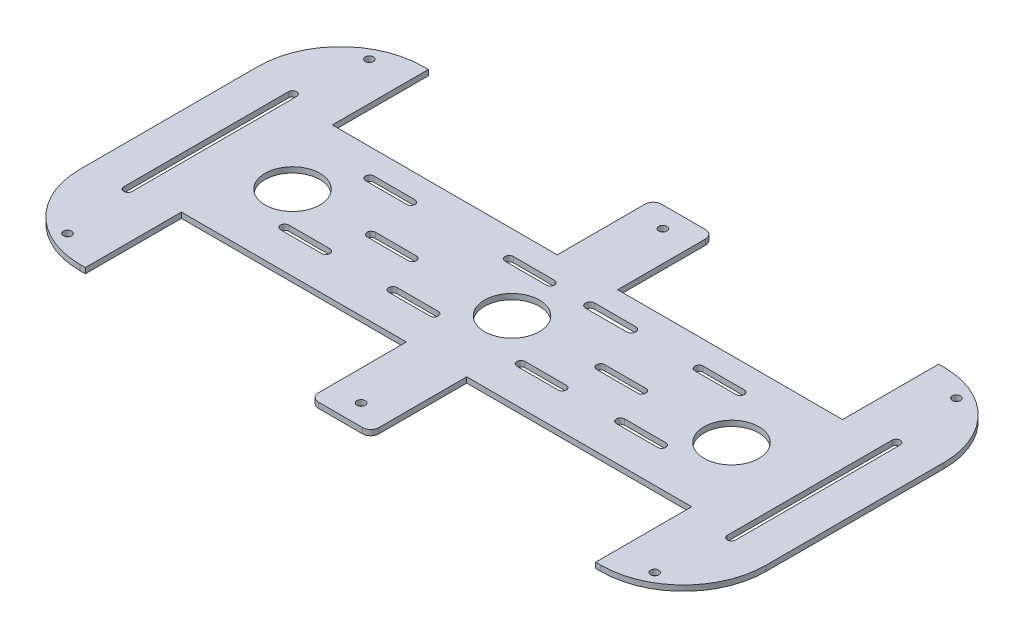
from build123d import *

# Parameters (mm, degrees)
SKETCH_1_R          = 10
EXTRUDE_1_DEPTH     = 2
FILLET_1_R          = 3
SKETCH_2_R          = 1.5
CUT_EXTRUDE_1_DEPTH = 3
SKETCH_3_R          = 1.5
CUT_EXTRUDE_2_DEPTH = 10


with BuildPart() as part:
    # 草图1 → 凸台-拉伸1 (new body)
    with BuildSketch(Plane(origin=(0, 0, 0), x_dir=(1, 0, 0), z_dir=(0, 1, 0))):
        with BuildLine():
            ThreePointArc((-125, -32.5), (-116.213203436, -53.713203436), (-95, -62.5))
            Line((-95, -62.5), (-93, -62.5))
            Line((-93, -62.5), (-93, -27.5))
            Line((-93, -27.5), (-11, -27.5))
            Line((-11, -27.5), (-11, -62.5))
            Line((-11, -62.5), (11, -62.5))
            Line((11, -62.5), (11, -27.5))
            Line((11, -27.5), (93, -27.5))
            Line((93, -27.5), (93, -62.5))
            Line((93, -62.5), (95, -62.5))
            ThreePointArc((95, -62.5), (116.213203436, -53.713203436), (125, -32.5))
            Line((125, -32.5), (125, 32.5))
            ThreePointArc((125, 32.5), (116.213203436, 53.713203436), (95, 62.5))
            Line((95, 62.5), (93, 62.5))
            Line((93, 62.5), (93, 27.5))
            Line((93, 27.5), (11, 27.5))
            Line((11, 27.5), (11, 62.5))
            Line((11, 62.5), (-11, 62.5))
            Line((-11, 62.5), (-11, 27.5))
            Line((-11, 27.5), (-93, 27.5))
            Line((-93, 27.5), (-93, 62.5))
            Line((-93, 62.5), (-95, 62.5))
            ThreePointArc((-95, 62.5), (-116.213203436, 53.713203436), (-125, 32.5))
            Line((-125, 32.5), (-125, -32.5))
        make_face()
        with BuildLine():
            ThreePointArc((-111.5, 30), (-110, 31.5), (-108.5, 30))
            Line((-108.5, 30), (-108.5, -30))
            ThreePointArc((-108.5, -30), (-110, -31.5), (-111.5, -30))
            Line((-111.5, -30), (-111.5, 30))
        make_face(mode=Mode.SUBTRACT)
        with Locations((-80, 0)):
            Circle(SKETCH_1_R, mode=Mode.SUBTRACT)
        with BuildLine():
            ThreePointArc((-69.340891424, -15.009353682), (-70.840891424, -13.509353682), (-69.340891424, -12.009353682))
            Line((-69.340891424, -12.009353682), (-54.340891424, -12.009353682))
            ThreePointArc((-54.340891424, -12.009353682), (-52.840891424, -13.509353682), (-54.340891424, -15.009353682))
            Line((-54.340891424, -15.009353682), (-69.340891424, -15.009353682))
        make_face(mode=Mode.SUBTRACT)
        with BuildLine():
            ThreePointArc((-51.302455724, -1.5), (-52.802455724, 0), (-51.302455724, 1.5))
            Line((-51.302455724, 1.5), (-36.302455724, 1.5))
            ThreePointArc((-36.302455724, 1.5), (-34.802455724, 0), (-36.302455724, -1.5))
            Line((-36.302455724, -1.5), (-51.302455724, -1.5))
        make_face(mode=Mode.SUBTRACT)
        with BuildLine():
            ThreePointArc((-29.892349798, -15.009353682), (-31.392349798, -13.509353682), (-29.892349798, -12.009353682))
            Line((-29.892349798, -12.009353682), (-14.892349798, -12.009353682))
            ThreePointArc((-14.892349798, -12.009353682), (-13.392349798, -13.509353682), (-14.892349798, -15.009353682))
            Line((-14.892349798, -15.009353682), (-29.892349798, -15.009353682))
        make_face(mode=Mode.SUBTRACT)
        with BuildLine():
            ThreePointArc((16.80528281, -15.009353682), (15.30528281, -13.509353682), (16.80528281, -12.009353682))
            Line((16.80528281, -12.009353682), (31.80528281, -12.009353682))
            ThreePointArc((31.80528281, -12.009353682), (33.30528281, -13.509353682), (31.80528281, -15.009353682))
            Line((31.80528281, -15.009353682), (16.80528281, -15.009353682))
        make_face(mode=Mode.SUBTRACT)
        with BuildLine():
            ThreePointArc((53.050737723, -15.009353682), (51.550737723, -13.509353682), (53.050737723, -12.009353682))
            Line((53.050737723, -12.009353682), (68.050737723, -12.009353682))
            ThreePointArc((68.050737723, -12.009353682), (69.550737723, -13.509353682), (68.050737723, -15.009353682))
            Line((68.050737723, -15.009353682), (53.050737723, -15.009353682))
        make_face(mode=Mode.SUBTRACT)
        with BuildLine():
            ThreePointArc((32.314965843, -1.5), (30.814965843, 0), (32.314965843, 1.5))
            Line((32.314965843, 1.5), (47.314965843, 1.5))
            ThreePointArc((47.314965843, 1.5), (48.814965843, 0), (47.314965843, -1.5))
            Line((47.314965843, -1.5), (32.314965843, -1.5))
        make_face(mode=Mode.SUBTRACT)
        with Locations((80, 0)):
            Circle(SKETCH_1_R, mode=Mode.SUBTRACT)
        with BuildLine():
            ThreePointArc((108.5, 30), (110, 31.5), (111.5, 30))
            Line((111.5, 30), (111.5, -30))
            ThreePointArc((111.5, -30), (110, -31.5), (108.5, -30))
            Line((108.5, -30), (108.5, 30))
        make_face(mode=Mode.SUBTRACT)
        with BuildLine():
            ThreePointArc((-69.340891424, 15.971420639), (-70.840891424, 17.471420639), (-69.340891424, 18.971420639))
            Line((-69.340891424, 18.971420639), (-54.340891424, 18.971420639))
            ThreePointArc((-54.340891424, 18.971420639), (-52.840891424, 17.471420639), (-54.340891424, 15.971420639))
            Line((-54.340891424, 15.971420639), (-69.340891424, 15.971420639))
        make_face(mode=Mode.SUBTRACT)
        with BuildLine():
            ThreePointArc((-18.5, 15.971420639), (-20, 17.471420639), (-18.5, 18.971420639))
            Line((-18.5, 18.971420639), (-3.5, 18.971420639))
            ThreePointArc((-3.5, 18.971420639), (-2, 17.471420639), (-3.5, 15.971420639))
            Line((-3.5, 15.971420639), (-18.5, 15.971420639))
        make_face(mode=Mode.SUBTRACT)
        Circle(SKETCH_1_R, mode=Mode.SUBTRACT)
        with BuildLine():
            ThreePointArc((11, 15.821420639), (9.35, 17.471420639), (11, 19.121420639))
            Line((11, 19.121420639), (26, 19.121420639))
            ThreePointArc((26, 19.121420639), (27.65, 17.471420639), (26, 15.821420639))
            Line((26, 15.821420639), (11, 15.821420639))
        make_face(mode=Mode.SUBTRACT)
        with BuildLine():
            ThreePointArc((50.690568566, 15.971420639), (49.190568566, 17.471420639), (50.690568566, 18.971420639))
            Line((50.690568566, 18.971420639), (65.690568566, 18.971420639))
            ThreePointArc((65.690568566, 18.971420639), (67.190568566, 17.471420639), (65.690568566, 15.971420639))
            Line((65.690568566, 15.971420639), (50.690568566, 15.971420639))
        make_face(mode=Mode.SUBTRACT)
    extrude(amount=EXTRUDE_1_DEPTH)

    # 圆角1
    fillet_1_edges = [part.edges().sort_by_distance(p)[0] for p in [
        (-11, 1, -62.5),
        (11, 1, -62.5),
        (11, 1, 62.5),
        (-11, 1, 62.5),
    ]]
    fillet(fillet_1_edges, radius=FILLET_1_R)

    # 草图2 → 切除-拉伸1 (cut, through all)
    with BuildSketch(Plane(origin=(0, 2, 0), x_dir=(1, 0, 0), z_dir=(0, 1, 0))):
        with Locations((107, -55)):
            Circle(SKETCH_2_R)
        with Locations((107, 55)):
            Circle(SKETCH_2_R)
        with Locations((-107, 55)):
            Circle(SKETCH_2_R)
        with Locations((-107, -55)):
            Circle(SKETCH_2_R)
    extrude(amount=-CUT_EXTRUDE_1_DEPTH, mode=Mode.SUBTRACT)

    # 草图3 → 切除-拉伸2 (cut)
    with BuildSketch(Plane.XZ):
        with Locations((0, 55)):
            Circle(SKETCH_3_R)
        with Locations((0, -55)):
            Circle(SKETCH_3_R)
    extrude(amount=-CUT_EXTRUDE_2_DEPTH, mode=Mode.SUBTRACT)


solid = part.part
